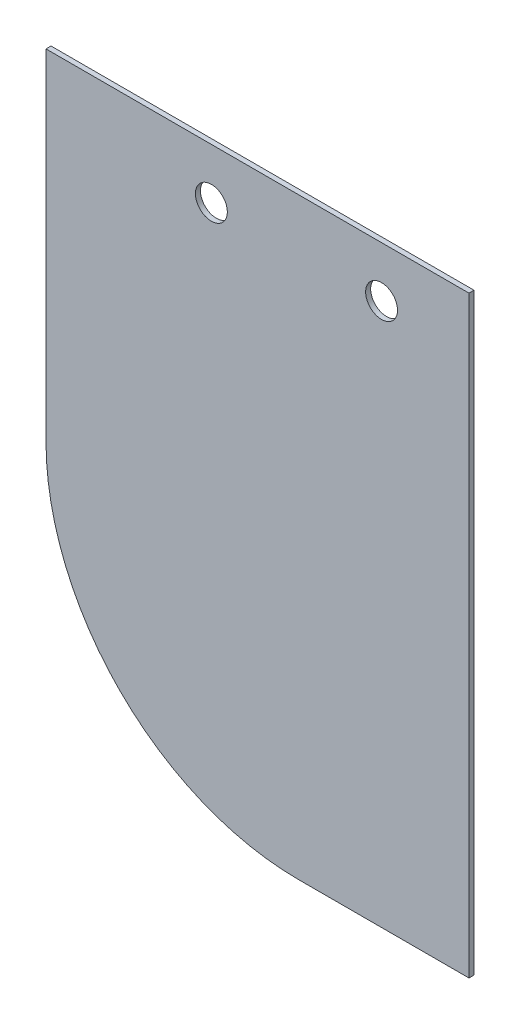
from build123d import *

# Parameters (mm, degrees)
SKETCH1_R      = 4.7625
EXTRUDE1_DEPTH = 1.5


with BuildPart() as part:
    # Sketch1 → Extrude1 (new body)
    with BuildSketch(Plane.XY):
        with BuildLine():
            Line((-418.175, 991.35), (-468.975, 991.35))
            ThreePointArc((-468.975, 991.35), (-522.326206641, 1013.448793359), (-544.425, 1066.8))
            Line((-544.425, 1066.8), (-544.425, 1168.4))
            Line((-544.425, 1168.4), (-418.175, 1168.4))
            Line((-418.175, 1168.4), (-418.175, 991.35))
        make_face()
        with Locations((-444.2625, 1153.3)):
            Circle(SKETCH1_R, mode=Mode.SUBTRACT)
        with Locations((-495.0625, 1153.3)):
            Circle(SKETCH1_R, mode=Mode.SUBTRACT)
    extrude(amount=EXTRUDE1_DEPTH)


solid = part.part
